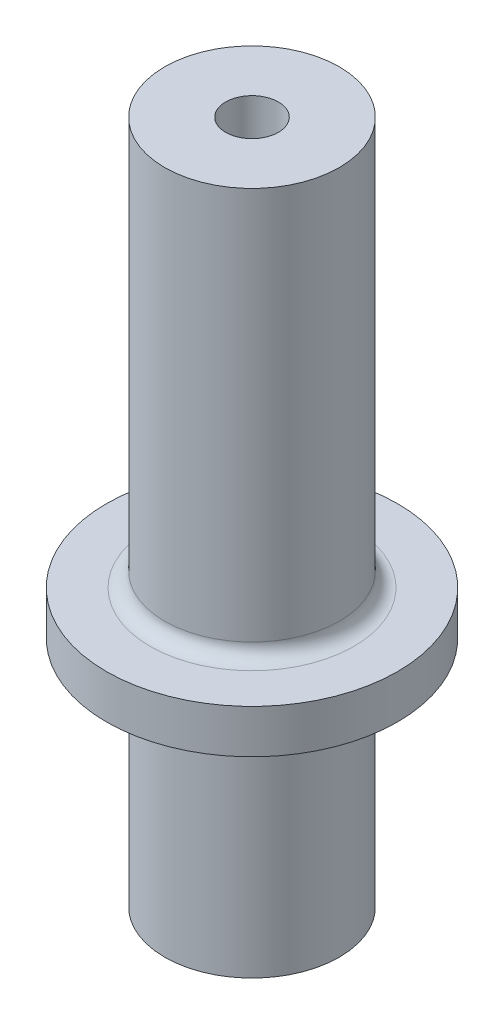
from build123d import *

# Parameters (mm, degrees)
F_1_2_20_TAPPED_HOLE1_D     = 11.50874
F_1_2_20_TAPPED_HOLE1_DEPTH = 29.21
F_1_2_20_TAPPED_HOLE1_TIP   = 3.45757432
FILLET1_R                   = 3.175


with BuildPart() as part:
    # Sketch1 → Revolve2 (revolve)
    with BuildSketch(Plane.XY):
        Polygon((-31.75, -2.966632853), (-31.75, 6.558367147), (-19.05, 6.558367147), (-19.05, 95.458367147), (0, 95.458367147), (0, 0), (0, -53.766632853), (-19.05, -53.766632853), (-19.05, -2.966632853), align=None)
    revolve(axis=Axis((0, 95.458367147, 0), (0, -1, 0)))

    # 1/2-20 Tapped Hole1
    with Locations(Plane.ZX.offset(95.458367147)):
        with Locations((0, 0)):
            Hole(F_1_2_20_TAPPED_HOLE1_D / 2, depth=F_1_2_20_TAPPED_HOLE1_DEPTH)
            with Locations((0, 0, -(F_1_2_20_TAPPED_HOLE1_DEPTH + F_1_2_20_TAPPED_HOLE1_TIP / 2))):  # 118° drill point
                Cone(0, F_1_2_20_TAPPED_HOLE1_D / 2, F_1_2_20_TAPPED_HOLE1_TIP, mode=Mode.SUBTRACT)

    # Fillet1
    fillet1_edges = [part.edges().sort_by_distance(p)[0] for p in [
        (19.05, 6.558367147, 0),
        (19.05, -2.966632853, 0),
    ]]
    fillet(fillet1_edges, radius=FILLET1_R)


solid = part.part
